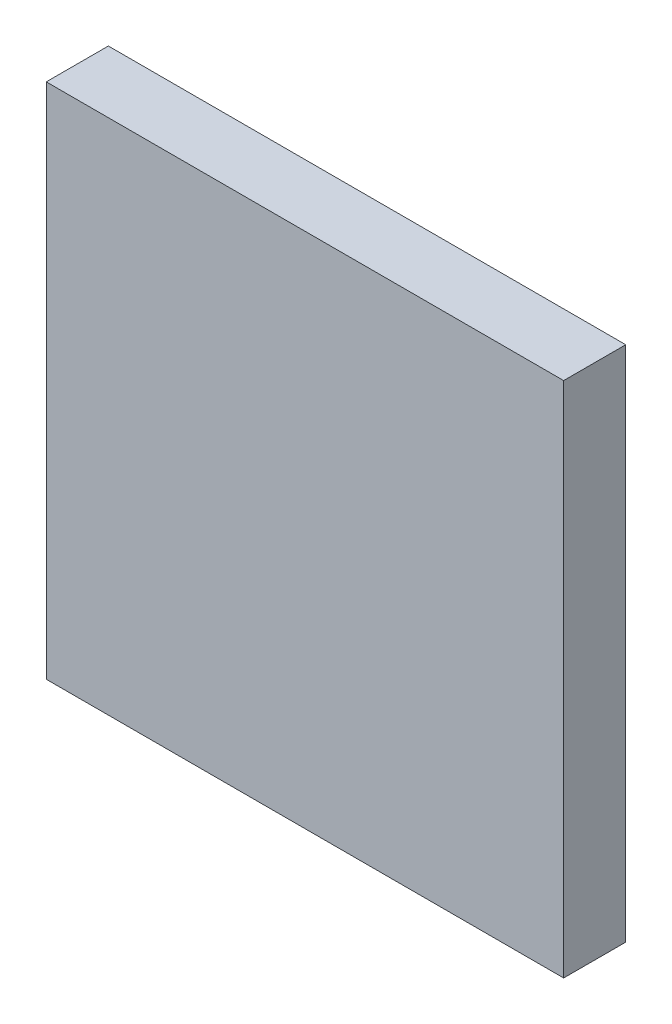
from build123d import *

# Parameters (mm, degrees)
SKETCH1_W           = 25
SKETCH1_H           = 25
BOSS_EXTRUDE1_DEPTH = 3


with BuildPart() as part:
    # Sketch1 → Boss-Extrude1 (new body)
    with BuildSketch(Plane.XY):
        Rectangle(SKETCH1_W, SKETCH1_H)
    extrude(amount=BOSS_EXTRUDE1_DEPTH)


solid = part.part
